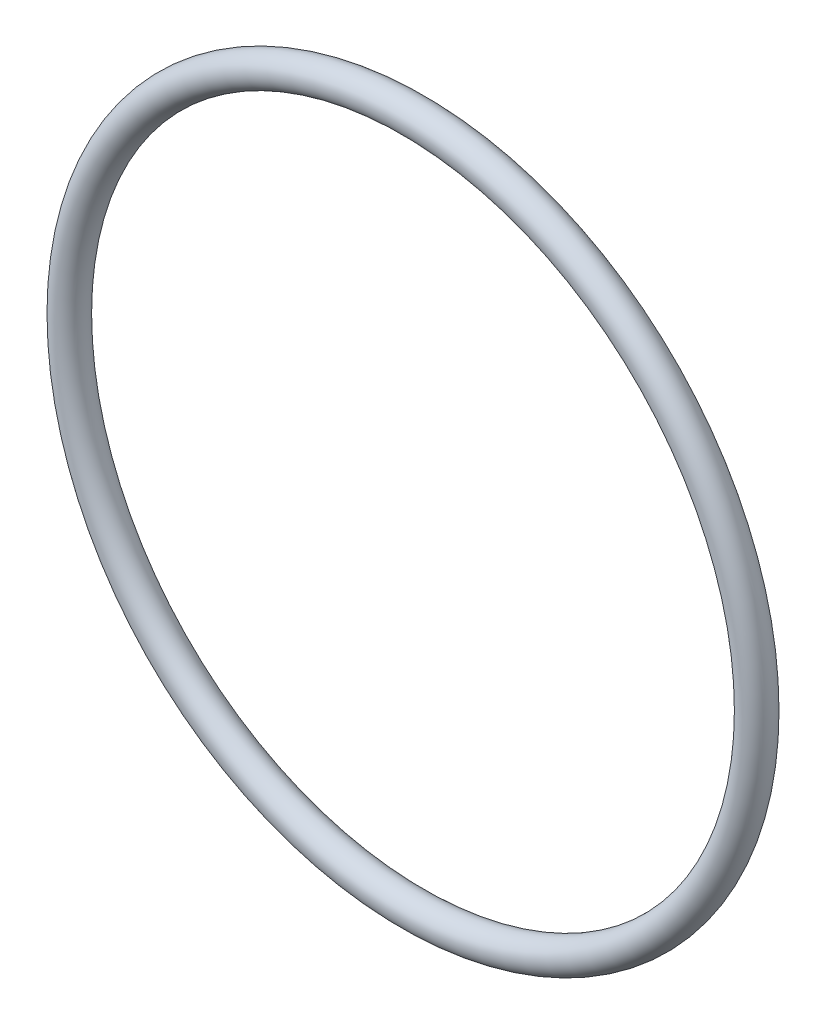
from build123d import *

# Parameters (mm, degrees)
SKETCH2_R = 1.55


with BuildPart() as part:
    # Sweep1: sweep along a path in Sketch1
    with BuildLine(Plane.XY) as sweep1_path:
        CenterArc((0, 0), 32.2, 0, 360)
    # Sketch2 → Sweep1 (sweep)
    with BuildSketch(Plane(origin=(0, 0, 0), x_dir=(1, 0, 0), z_dir=(0, 1, 0))):
        with Locations((-33.75, 0)):
            Circle(SKETCH2_R)
    sweep(path=sweep1_path.line)


solid = part.part
